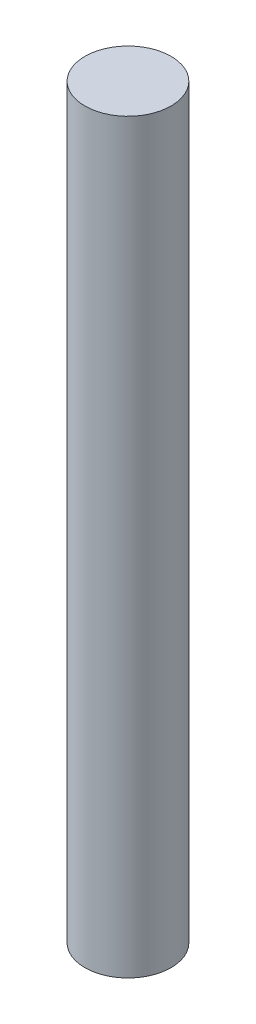
from build123d import *

# Parameters (mm, degrees)
SKETCH1_R           = 1.905
BOSS_EXTRUDE1_DEPTH = 33.02


with BuildPart() as part:
    # Sketch1 → Boss-Extrude1 (new body)
    with BuildSketch(Plane(origin=(0, 0, 0), x_dir=(1, 0, 0), z_dir=(0, 1, 0))):
        Circle(SKETCH1_R)
    extrude(amount=BOSS_EXTRUDE1_DEPTH)


solid = part.part
